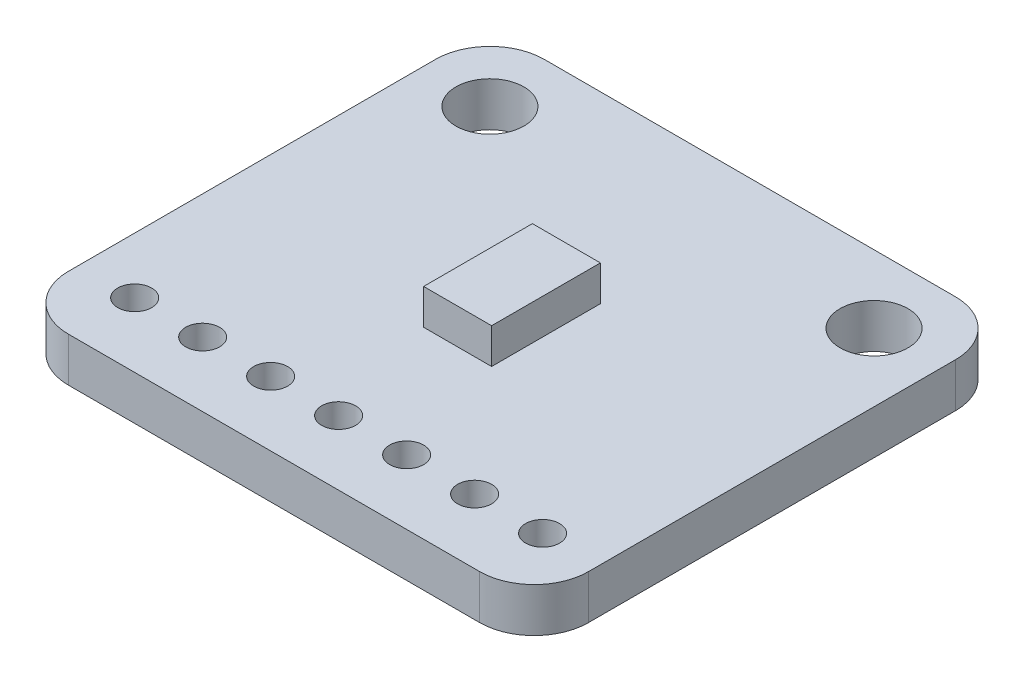
from build123d import *

# Parameters (mm, degrees)
SKETCH1_R           = 1.27
SKETCH1_R_2         = 0.635
BOSS_EXTRUDE1_DEPTH = 1.651
SKETCH2_W           = 1.27
SKETCH2_H           = 2.032
BOSS_EXTRUDE2_DEPTH = 1.3208


with BuildPart() as part:
    # Sketch1 → Boss-Extrude1 (new body)
    with BuildSketch(Plane(origin=(0, 0, 0), x_dir=(1, 0, 0), z_dir=(0, 1, 0))):
        with BuildLine():
            Line((2.032, 0), (17.399, 0))
            ThreePointArc((17.399, 0), (18.835840979, 0.595159021), (19.431, 2.032))
            Line((19.431, 2.032), (19.431, 15.748))
            ThreePointArc((19.431, 15.748), (18.835840979, 17.184840979), (17.399, 17.78))
            Line((17.399, 17.78), (2.032, 17.78))
            ThreePointArc((2.032, 17.78), (0.595159021, 17.184840979), (0, 15.748))
            Line((0, 15.748), (0, 2.032))
            ThreePointArc((0, 2.032), (0.595159021, 0.595159021), (2.032, 0))
        make_face()
        with Locations((2.54, 15.24)):
            Circle(SKETCH1_R, mode=Mode.SUBTRACT)
        with Locations((16.891, 15.24)):
            Circle(SKETCH1_R, mode=Mode.SUBTRACT)
        with Locations((2.0955, 2.413)):
            Circle(SKETCH1_R_2, mode=Mode.SUBTRACT)
        with Locations((4.6355, 2.413)):
            Circle(SKETCH1_R_2, mode=Mode.SUBTRACT)
        with Locations((7.1755, 2.413)):
            Circle(SKETCH1_R_2, mode=Mode.SUBTRACT)
        with Locations((9.7155, 2.413)):
            Circle(SKETCH1_R_2, mode=Mode.SUBTRACT)
        with Locations((12.2555, 2.413)):
            Circle(SKETCH1_R_2, mode=Mode.SUBTRACT)
        with Locations((14.7955, 2.413)):
            Circle(SKETCH1_R_2, mode=Mode.SUBTRACT)
        with Locations((17.3355, 2.413)):
            Circle(SKETCH1_R_2, mode=Mode.SUBTRACT)
    extrude(amount=BOSS_EXTRUDE1_DEPTH)

    # Sketch2 → Boss-Extrude2 (add)
    with BuildSketch(Plane(origin=(0, 1.651, 0), x_dir=(1, 0, 0), z_dir=(0, 1, 0))):
        with Locations((9.0805, 7.874)):
            Rectangle(SKETCH2_W, SKETCH2_H)
        Polygon((8.4455, 8.89), (9.7155, 8.89), (9.7155, 6.858), (10.9855, 6.858), (10.9855, 10.922), (8.4455, 10.922), align=None)
    extrude(amount=BOSS_EXTRUDE2_DEPTH)


solid = part.part
